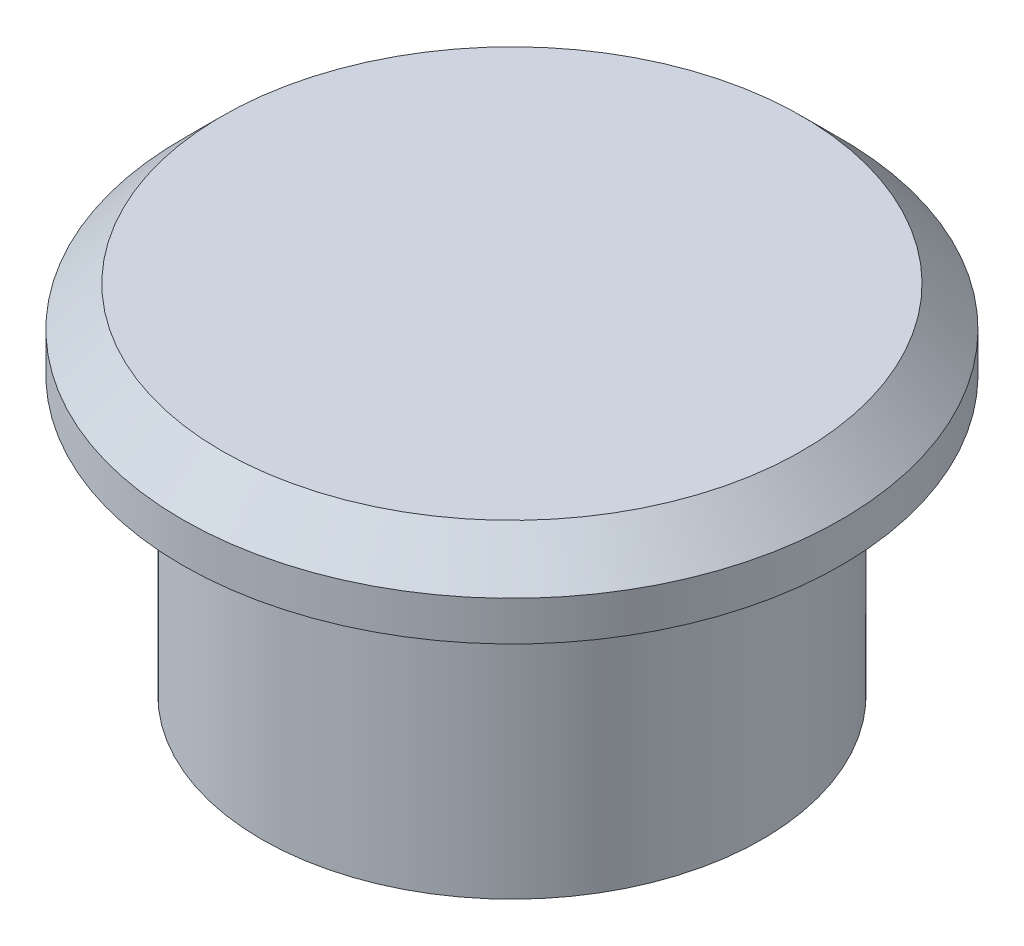
from build123d import *

# Parameters (mm, degrees)
SKETCH1_R           = 6.33
BOSS_EXTRUDE1_DEPTH = 7
SKETCH2_R           = 4.691712698
CUT_EXTRUDE1_DEPTH  = 7
SKETCH3_R           = 8.33
BOSS_EXTRUDE2_DEPTH = 2
CHAMFER1_SIZE       = 1


with BuildPart() as part:
    # Sketch1 → Boss-Extrude1 (new body)
    with BuildSketch(Plane(origin=(0, 0, 0), x_dir=(1, 0, 0), z_dir=(0, 1, 0))):
        Circle(SKETCH1_R)
    extrude(amount=BOSS_EXTRUDE1_DEPTH)

    # Sketch2 → Cut-Extrude1 (cut)
    with BuildSketch(Plane(origin=(0, 7, 0), x_dir=(1, 0, 0), z_dir=(0, 1, 0))):
        Circle(SKETCH2_R)
    extrude(amount=-CUT_EXTRUDE1_DEPTH, mode=Mode.SUBTRACT)

    # Sketch3 → Boss-Extrude2 (add)
    with BuildSketch(Plane(origin=(0, 7, 0), x_dir=(1, 0, 0), z_dir=(0, 1, 0))):
        Circle(SKETCH3_R)
    extrude(amount=BOSS_EXTRUDE2_DEPTH)

    # Chamfer1
    chamfer1_edges = [part.edges().sort_by_distance(p)[0] for p in [
        (-8.33, 9, 0),
    ]]
    chamfer(chamfer1_edges, length=CHAMFER1_SIZE)


solid = part.part
